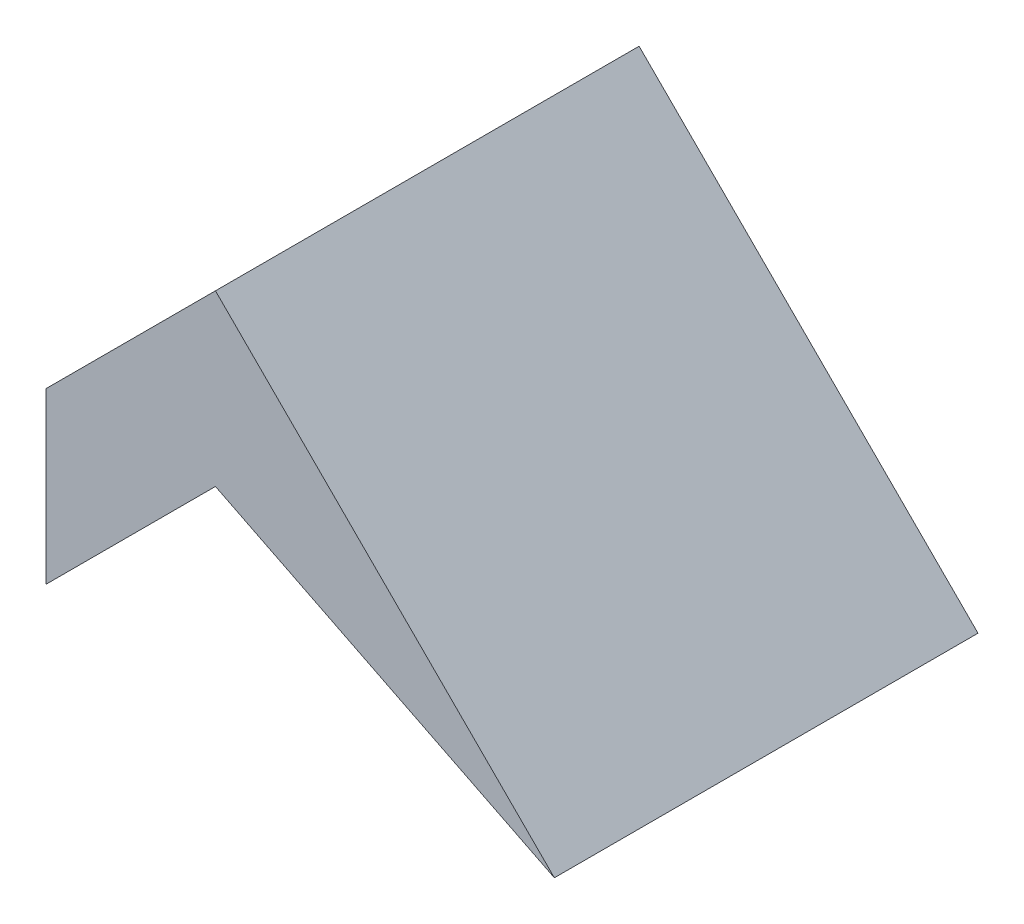
from build123d import *

# Parameters (mm, degrees)
BOSS_EXTRUDE3_DEPTH = 25


with BuildPart() as part:
    # Sketch1 → Boss-Extrude3 (new body)
    with BuildSketch(Plane.XY):
        Polygon((-10, -10), (0, 0), (20, -20), (0, -10), (-10, -20), align=None)
    extrude(amount=BOSS_EXTRUDE3_DEPTH)


solid = part.part
